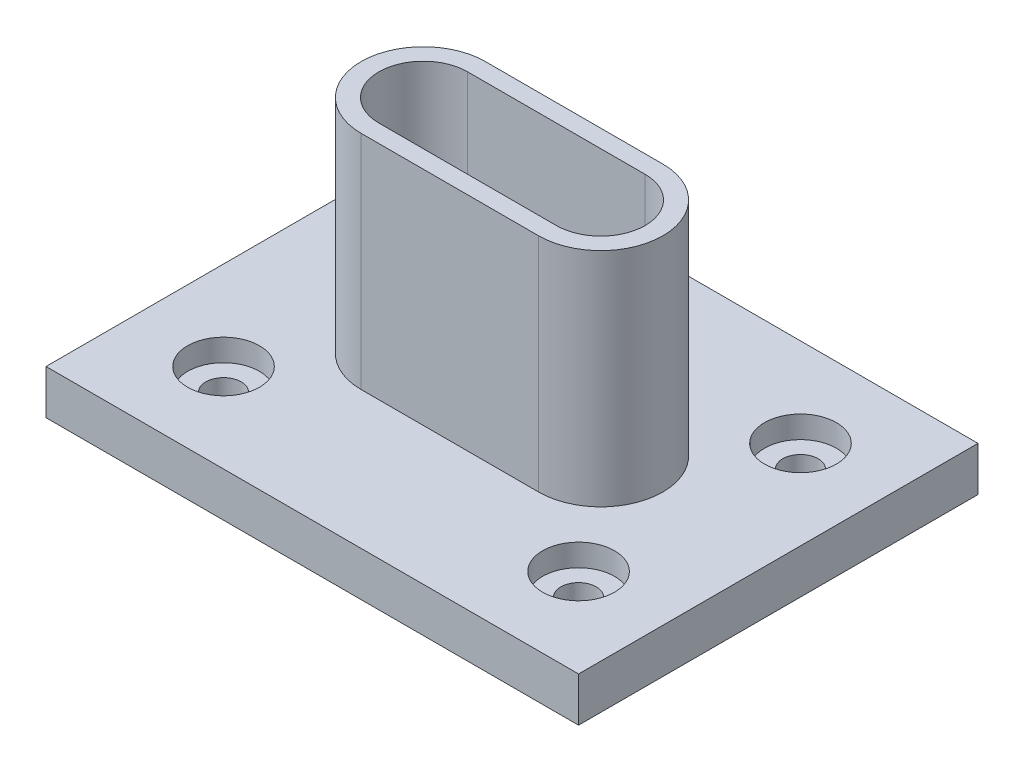
from build123d import *

# Parameters (mm, degrees)
SKETCH1_W           = 152.4
SKETCH1_H           = 114.3
SKETCH1_R           = 10.287
BOSS_EXTRUDE1_DEPTH = 12.7
EXTRUDE_THIN1_DEPTH = 63.5
SKETCH1_4_R         = 10.287
SKETCH1_4_R_2       = 5.08
BOSS_EXTRUDE2_DEPTH = 12.7
SKETCH1_5_R         = 10.287
SKETCH1_5_R_2       = 5.08
CUT_EXTRUDE1_DEPTH  = 6.35


with BuildPart() as part:
    # Sketch1 → Boss-Extrude1 (new body)
    with BuildSketch(Plane(origin=(0, 0, 0), x_dir=(1, 0, 0), z_dir=(0, 1, 0))):
        Rectangle(SKETCH1_W, SKETCH1_H)
        with Locations((-50.8, 31.75)):
            Circle(SKETCH1_R, mode=Mode.SUBTRACT)
        with Locations((50.8, 31.75)):
            Circle(SKETCH1_R, mode=Mode.SUBTRACT)
        with Locations((50.8, -31.75)):
            Circle(SKETCH1_R, mode=Mode.SUBTRACT)
        with Locations((-50.8, -31.75)):
            Circle(SKETCH1_R, mode=Mode.SUBTRACT)
        with BuildLine():
            ThreePointArc((25.4, -12.7), (38.1, 0), (25.4, 12.7))
            Line((25.4, 12.7), (-25.4, 12.7))
            ThreePointArc((-25.4, 12.7), (-38.1, 0), (-25.4, -12.7))
            Line((-25.4, -12.7), (25.4, -12.7))
        make_face(mode=Mode.SUBTRACT)
    extrude(amount=-BOSS_EXTRUDE1_DEPTH)

    # Sketch1_3 → Extrude-Thin1 (add)
    with BuildSketch(Plane(origin=(0, 0, 0), x_dir=(1, 0, 0), z_dir=(0, 1, 0))):
        with BuildLine():
            Line((25.4, -17.78), (-25.4, -17.78))
            ThreePointArc((-25.4, -17.78), (-43.18, 0), (-25.4, 17.78))
            Line((-25.4, 17.78), (25.4, 17.78))
            ThreePointArc((25.4, 17.78), (43.18, 0), (25.4, -17.78))
        make_face()
        with BuildLine():
            Line((25.4, -12.7), (-25.4, -12.7))
            ThreePointArc((-25.4, -12.7), (-38.1, 0), (-25.4, 12.7))
            Line((-25.4, 12.7), (25.4, 12.7))
            ThreePointArc((25.4, 12.7), (38.1, 0), (25.4, -12.7))
        make_face(mode=Mode.SUBTRACT)
    extrude(amount=EXTRUDE_THIN1_DEPTH)

    # Sketch1_4 → Boss-Extrude2 (add)
    with BuildSketch(Plane(origin=(0, 0, 0), x_dir=(1, 0, 0), z_dir=(0, 1, 0))):
        with Locations((-50.8, 31.75)):
            Circle(SKETCH1_4_R)
        with Locations((-50.8, 31.75)):
            Circle(SKETCH1_4_R_2, mode=Mode.SUBTRACT)
        with Locations((-50.8, -31.75)):
            Circle(SKETCH1_4_R)
        with Locations((-50.8, -31.75)):
            Circle(SKETCH1_4_R_2, mode=Mode.SUBTRACT)
        with Locations((50.8, -31.75)):
            Circle(SKETCH1_4_R)
        with Locations((50.8, -31.75)):
            Circle(SKETCH1_4_R_2, mode=Mode.SUBTRACT)
        with Locations((50.8, 31.75)):
            Circle(SKETCH1_4_R)
        with Locations((50.8, 31.75)):
            Circle(SKETCH1_4_R_2, mode=Mode.SUBTRACT)
    extrude(amount=-BOSS_EXTRUDE2_DEPTH)

    # Sketch1_5 → Cut-Extrude1 (cut)
    with BuildSketch(Plane(origin=(0, 0, 0), x_dir=(1, 0, 0), z_dir=(0, 1, 0))):
        with Locations((-50.8, -31.75)):
            Circle(SKETCH1_5_R)
        with Locations((-50.8, -31.75)):
            Circle(SKETCH1_5_R_2, mode=Mode.SUBTRACT)
        with Locations((-50.8, 31.75)):
            Circle(SKETCH1_5_R)
        with Locations((-50.8, 31.75)):
            Circle(SKETCH1_5_R_2, mode=Mode.SUBTRACT)
        with Locations((50.8, 31.75)):
            Circle(SKETCH1_5_R)
        with Locations((50.8, 31.75)):
            Circle(SKETCH1_5_R_2, mode=Mode.SUBTRACT)
        with Locations((50.8, -31.75)):
            Circle(SKETCH1_5_R)
        with Locations((50.8, -31.75)):
            Circle(SKETCH1_5_R_2, mode=Mode.SUBTRACT)
    extrude(amount=-CUT_EXTRUDE1_DEPTH, mode=Mode.SUBTRACT)


solid = part.part
